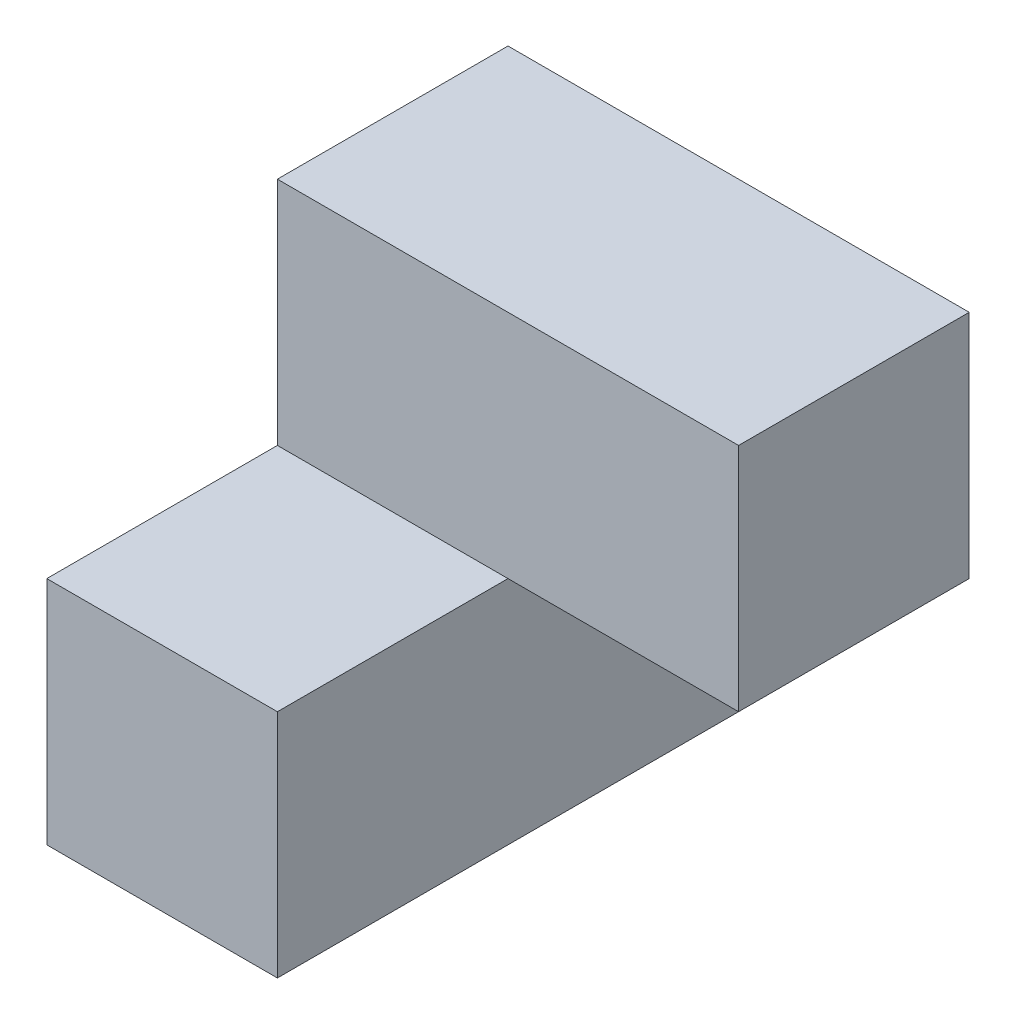
from build123d import *

# Parameters (mm, degrees)
SKETCH1_W           = 50.8
SKETCH1_H           = 50.8
BOSS_EXTRUDE1_DEPTH = 25.4
CUT_EXTRUDE1_REACH  = 52.8
SKETCH2_W           = 50.8
SKETCH2_H           = 50.8
CUT_EXTRUDE2_REACH  = 27.4
SKETCH4_W           = 25.4
SKETCH4_H           = 25.4
CUT_EXTRUDE3_REACH  = 27.4
SKETCH5_W           = 25.4
SKETCH5_H           = 25.4


with BuildPart() as part:
    # Sketch1 → Boss-Extrude1 (new body, symmetric)
    with BuildSketch(Plane(origin=(0, 0, 0), x_dir=(1, 0, 0), z_dir=(0, 1, 0))):
        Rectangle(SKETCH1_W, SKETCH1_H)
    extrude(amount=BOSS_EXTRUDE1_DEPTH, both=True)

    # Sketch2 → Cut-Extrude1 (cut, up to next)
    with BuildSketch(Plane(origin=(0, 25.4, 0), x_dir=(1, 0, 0), z_dir=(0, 1, 0)), mode=Mode.PRIVATE) as cut_extrude1_sk1:
        with Locations((25.4, -25.4)):
            Rectangle(SKETCH2_W, SKETCH2_H)
    cut_extrude1_tool1 = extrude(cut_extrude1_sk1.sketch, amount=-CUT_EXTRUDE1_REACH, mode=Mode.PRIVATE) & part.part
    add(cut_extrude1_tool1.solids().sort_by_distance((25.4, 25.4, 25.4))[0], mode=Mode.SUBTRACT)

    # Sketch4 → Cut-Extrude2 (cut, up to next)
    with BuildSketch(Plane(origin=(0, 0, 0), x_dir=(0, 0, -1), z_dir=(1, 0, 0)), mode=Mode.PRIVATE) as cut_extrude2_sk1:
        with Locations((-12.7, 12.7)):
            Rectangle(SKETCH4_W, SKETCH4_H)
    cut_extrude2_tool1 = extrude(cut_extrude2_sk1.sketch, amount=-CUT_EXTRUDE2_REACH, mode=Mode.PRIVATE) & part.part
    add(cut_extrude2_tool1.solids().sort_by_distance((0, 12.7, 12.7))[0], mode=Mode.SUBTRACT)

    # Sketch5 → Cut-Extrude3 (cut, up to next)
    with BuildSketch(Plane.XY, mode=Mode.PRIVATE) as cut_extrude3_sk1:
        with Locations((12.7, -12.7)):
            Rectangle(SKETCH5_W, SKETCH5_H)
    cut_extrude3_tool1 = extrude(cut_extrude3_sk1.sketch, amount=-CUT_EXTRUDE3_REACH, mode=Mode.PRIVATE) & part.part
    add(cut_extrude3_tool1.solids().sort_by_distance((12.7, -12.7, 0))[0], mode=Mode.SUBTRACT)


solid = part.part
